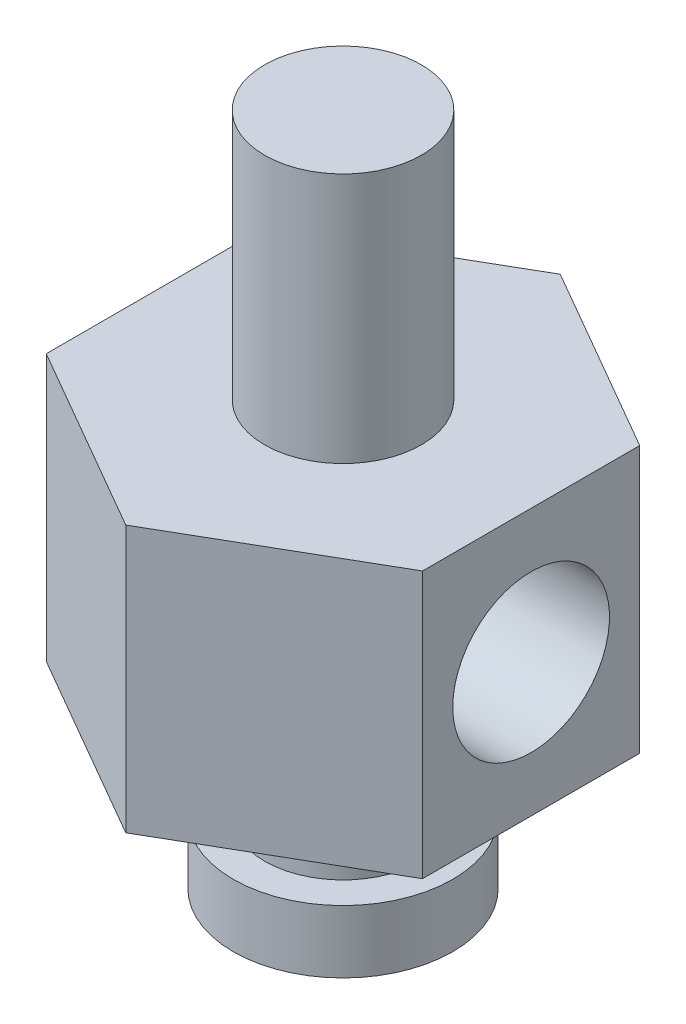
from build123d import *

# Parameters (mm, degrees)
ESQUISSE1_R             = 3.5
ESQUISSE1_R_2           = 1.5
BOSS_EXTRU_1_DEPTH      = 2
ESQUISSE2_R             = 2.5
ESQUISSE2_R_2           = 1.5
BOSS_EXTRU_2_DEPTH      = 3
ESQUISSE3_R             = 1.5
BOSS_EXTRU_3_DEPTH      = 8.5
ESQUISSE4_R             = 2.5
BOSS_EXTRU_4_DEPTH      = 8
ESQUISSE5_R             = 2.5
ENL_V_MAT_EXTRU_1_DEPTH = 12


with BuildPart() as part:
    # Esquisse1 → Boss.-Extru.1 (new body)
    with BuildSketch(Plane(origin=(0, 0, 0), x_dir=(1, 0, 0), z_dir=(0, 1, 0))):
        Circle(ESQUISSE1_R)
        Circle(ESQUISSE1_R_2, mode=Mode.SUBTRACT)
    extrude(amount=BOSS_EXTRU_1_DEPTH)

    # Esquisse2 → Boss.-Extru.2 (add)
    with BuildSketch(Plane(origin=(0, 2, 0), x_dir=(1, 0, 0), z_dir=(0, 1, 0))):
        Circle(ESQUISSE2_R)
        Circle(ESQUISSE2_R_2, mode=Mode.SUBTRACT)
    extrude(amount=BOSS_EXTRU_2_DEPTH)

    # Esquisse3 → Boss.-Extru.3 (add)
    with BuildSketch(Plane(origin=(0, 5, 0), x_dir=(1, 0, 0), z_dir=(0, 1, 0))):
        Polygon((-6, 3.464101615), (-6, -3.464101615), (0, -6.92820323), (6, -3.464101615), (6, 3.464101615), (0, 6.92820323), align=None)
        Circle(ESQUISSE3_R, mode=Mode.SUBTRACT)
    extrude(amount=BOSS_EXTRU_3_DEPTH)

    # Esquisse4 → Boss.-Extru.4 (add)
    with BuildSketch(Plane(origin=(0, 13.5, 0), x_dir=(1, 0, 0), z_dir=(0, 1, 0))):
        Circle(ESQUISSE4_R)
    extrude(amount=BOSS_EXTRU_4_DEPTH)

    # Esquisse5 → Enlèv. mat.-Extru.1 (cut)
    with BuildSketch(Plane.ZY.offset(6)):
        with Locations((0, 9.25)):
            Circle(ESQUISSE5_R)
    extrude(amount=-ENL_V_MAT_EXTRU_1_DEPTH, mode=Mode.SUBTRACT)


solid = part.part
